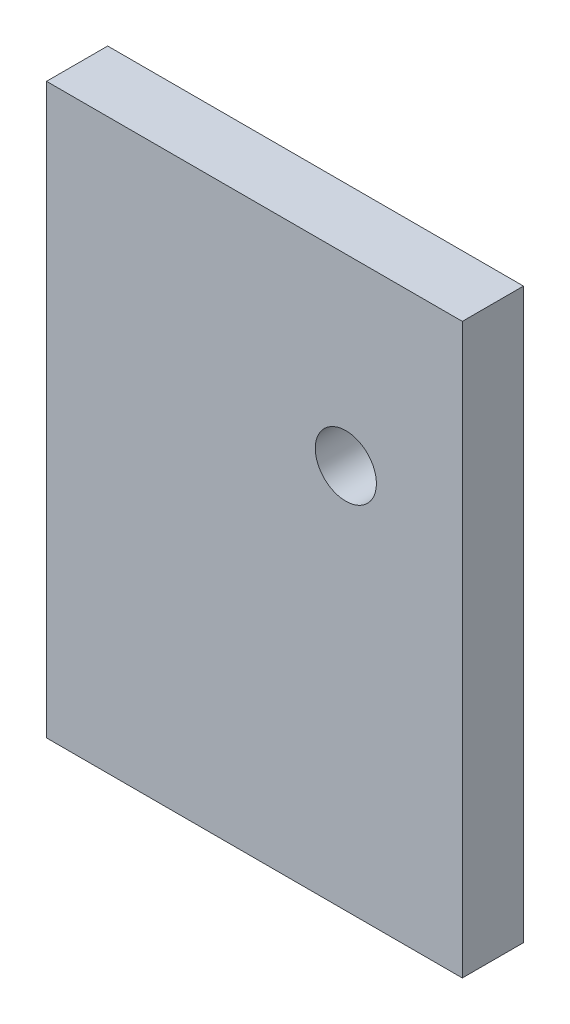
from build123d import *

# Parameters (mm, degrees)
CROQUIS1_W              = 68
CROQUIS1_H              = 93
SALIENTE_EXTRUIR1_DEPTH = 10
CROQUIS2_R              = 5
CORTAR_EXTRUIR1_DEPTH   = 11


with BuildPart() as part:
    # Croquis1 → Saliente-Extruir1 (new body)
    with BuildSketch(Plane.XY):
        with Locations((-20.827735365, 1.651223582)):
            Rectangle(CROQUIS1_W, CROQUIS1_H)
    extrude(amount=SALIENTE_EXTRUIR1_DEPTH)

    # Croquis2 → Cortar-Extruir1 (cut, through all)
    with BuildSketch(Plane.XY.offset(10)):
        with Locations((-5.877735365, 18.151223582)):
            Circle(CROQUIS2_R)
    extrude(amount=-CORTAR_EXTRUIR1_DEPTH, mode=Mode.SUBTRACT)


solid = part.part
